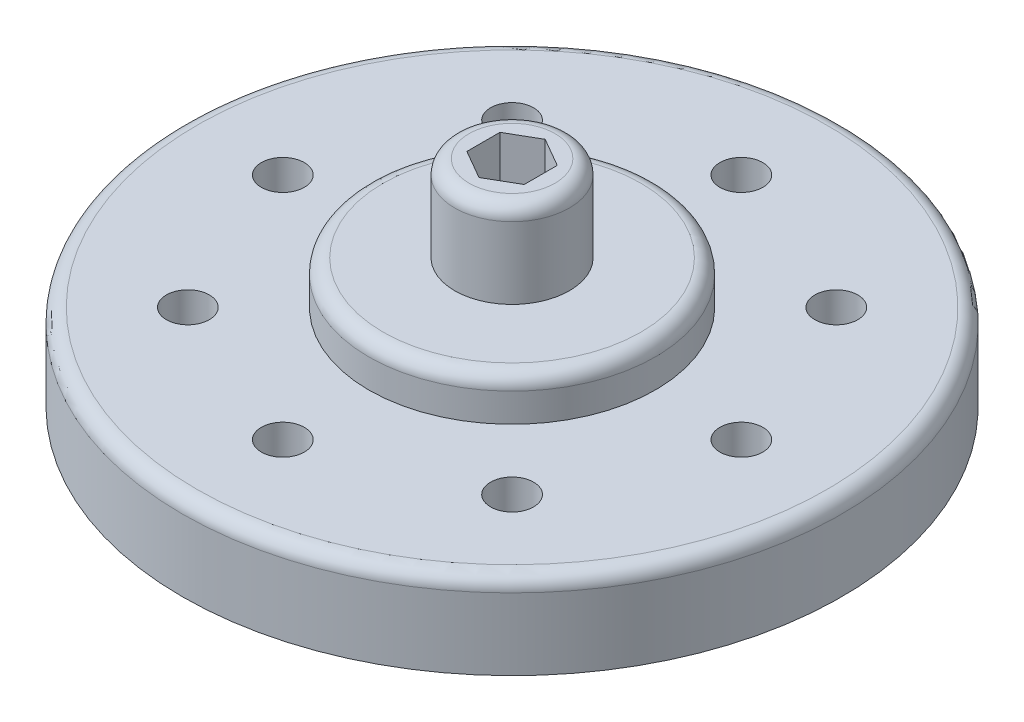
from build123d import *

# Parameters (mm, degrees)
CROQUIS1_R              = 11.5
SALIENTE_EXTRUIR1_DEPTH = 3
CROQUIS1_9_R            = 0.75
CORTAR_EXTRUIR2_DEPTH   = 3
MATRIZC2_COUNT          = 8
SALIENTE_EXTRUIR2_START = 3
CROQUIS1_11_R           = 5
SALIENTE_EXTRUIR2_DEPTH = 1.5
SALIENTE_EXTRUIR3_START = 4.5
CROQUIS1_12_R           = 2
SALIENTE_EXTRUIR3_DEPTH = 3
REDONDEO1_R             = 0.5
CROQUIS1_13_R           = 5
CROQUIS1_13_R_2         = 2
SALIENTE_EXTRUIR4_DEPTH = 1


with BuildPart() as part:
    # Croquis1 → Saliente-Extruir1 (new body)
    with BuildSketch(Plane(origin=(0, 0, 0), x_dir=(1, 0, 0), z_dir=(0, 1, 0))):
        with Locations((0, 13.3)):
            Circle(CROQUIS1_R)
    extrude(amount=SALIENTE_EXTRUIR1_DEPTH)

    # Croquis1_9 → Cortar-Extruir2 (cut)
    with BuildSketch(Plane(origin=(0, 0, 0), x_dir=(1, 0, 0), z_dir=(0, 1, 0))):
        with Locations((0, 21.3)):
            Circle(CROQUIS1_9_R)
    cortar_extruir2 = extrude(amount=CORTAR_EXTRUIR2_DEPTH, mode=Mode.SUBTRACT)

    # MatrizC2: Cortar-Extruir2 ×8 about axis
    matrizc2_axis = Axis((0, 0, -13.3), (0, 1, 0))
    for i in range(1, MATRIZC2_COUNT):
        add(cortar_extruir2.rotate(matrizc2_axis, i * 360 / MATRIZC2_COUNT), mode=Mode.SUBTRACT)

    # Croquis1_11 → Saliente-Extruir2 (add)
    with BuildSketch(Plane(origin=(0, 0, 0), x_dir=(1, 0, 0), z_dir=(0, 1, 0)).offset(SALIENTE_EXTRUIR2_START)):
        with Locations((0, 13.3)):
            Circle(CROQUIS1_11_R)
    extrude(amount=SALIENTE_EXTRUIR2_DEPTH)

    # Croquis1_12 → Saliente-Extruir3 (add)
    with BuildSketch(Plane(origin=(0, 0, 0), x_dir=(1, 0, 0), z_dir=(0, 1, 0)).offset(SALIENTE_EXTRUIR3_START)):
        with Locations((0, 13.3)):
            Circle(CROQUIS1_12_R)
        Polygon((1, 12.722649731), (1, 13.877350269), (0, 14.454700538), (-1, 13.877350269), (-1, 12.722649731), (0, 12.145299462), align=None, mode=Mode.SUBTRACT)
    extrude(amount=SALIENTE_EXTRUIR3_DEPTH)

    # Redondeo1
    redondeo1_edges = [part.edges().sort_by_distance(p)[0] for p in [
        (-11.5, 3, -13.3),
        (-5, 4.5, -13.3),
        (-2, 7.5, -13.3),
    ]]
    fillet(redondeo1_edges, radius=REDONDEO1_R)

    # Croquis1_13 → Saliente-Extruir4 (add)
    with BuildSketch(Plane(origin=(0, 0, 0), x_dir=(1, 0, 0), z_dir=(0, 1, 0))):
        with Locations((0, 13.3)):
            Circle(CROQUIS1_13_R)
        with Locations((0, 13.3)):
            Circle(CROQUIS1_13_R_2, mode=Mode.SUBTRACT)
    extrude(amount=-SALIENTE_EXTRUIR4_DEPTH)


solid = part.part
